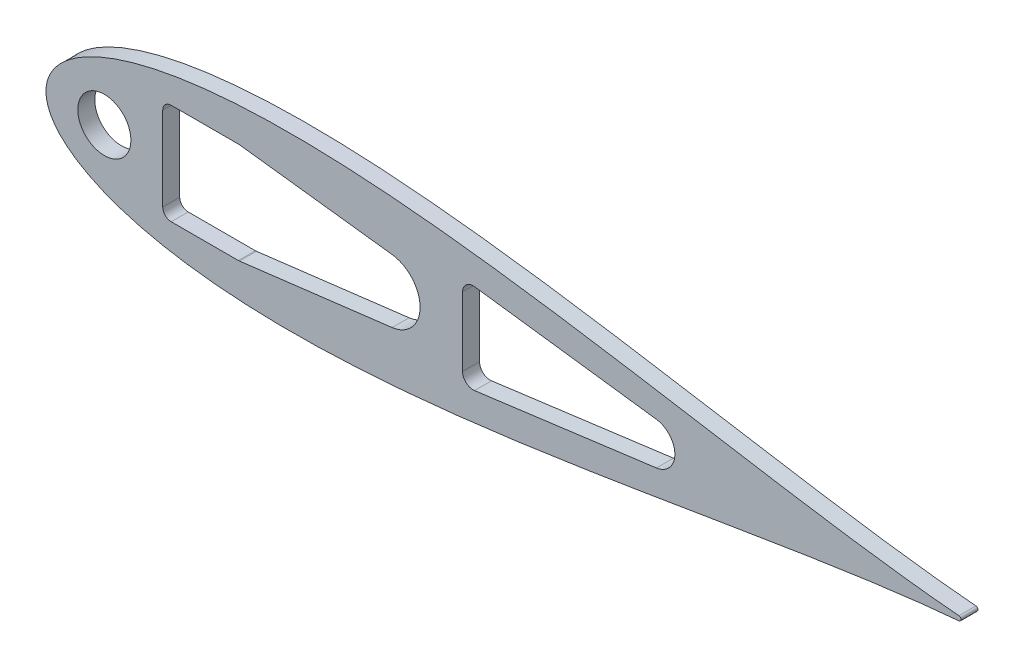
from build123d import *

# Parameters (mm, degrees)
BOSS_EXTRUDE1_DEPTH = 5.4737
SCALE1_SCALE        = 0.425
BOSS_EXTRUDE2_DEPTH = 5.08
SKETCH10_W          = 25.167167629
SKETCH10_H          = 30.1625
CUT_EXTRUDE6_DEPTH  = 6.0800001
FILLET1_R           = 2.54
CUT_EXTRUDE8_DEPTH  = 6.0800001
CUT_EXTRUDE9_DEPTH  = 6.0800001
SKETCH19_R          = 7.9375
CUT_EXTRUDE10_DEPTH = 6.0800001


with BuildPart() as part:
    # Sketch2 → Boss-Extrude1 (new body)
    with BuildSketch(Plane.XY):
        with BuildLine():
            add(Edge.make_bspline(
                [(642.510849283, 1.582039112), (641.993392355, 1.625070631), (638.093728429, 1.953546407), (630.413817462, 2.663385493), (619.014124193, 3.849253664), (606.374988512, 5.304428983), (592.543922516, 7.037634907), (577.585454095, 9.050636147), (561.564270734, 11.338919625), (544.549749946, 13.890665375), (526.614143658, 16.687720753), (507.832591566, 19.705111663), (488.282710288, 22.911672601), (468.044367735, 26.27043606), (447.199424328, 29.739007432), (425.831595832, 33.270324121), (404.02631566, 36.813220545), (381.870662856, 40.313266856), (359.453314895, 43.713502532), (336.86454415, 46.955447457), (314.196207315, 49.979843895), (291.541767704, 52.727712704), (268.996310773, 55.141201012), (246.65655865, 57.164603829), (224.620860897, 58.745176641), (202.989192599, 59.8341217), (181.863132616, 60.387506142), (161.345829027, 60.366961324), (141.542033828, 59.739895824), (122.558104573, 58.481758104), (104.502313427, 56.574303932), (87.485018636, 54.008935199), (71.619696083, 50.784752003), (57.023709725, 46.912543066), (43.82045433, 42.41500246), (32.141645239, 37.332204029), (22.129107375, 31.731455339), (13.932423524, 25.726412106), (7.689616489, 19.513207632), (3.463136343, 13.420354421), (1.106333228, 7.923389435), (0.154611582, 3.513796615), (-0.062151598, 0), (0.154611582, -3.513796615), (1.106333228, -7.923389435), (3.463136343, -13.420354421), (7.689616489, -19.513207632), (13.932423524, -25.726412106), (22.129107375, -31.731455339), (32.141645239, -37.332204029), (43.82045433, -42.41500246), (57.023709725, -46.912543066), (71.619696083, -50.784752003), (87.485018636, -54.008935199), (104.502313427, -56.574303932), (122.558104573, -58.481758104), (141.542033828, -59.739895824), (161.345829027, -60.366961324), (181.863132616, -60.387506142), (202.989192599, -59.8341217), (224.620860897, -58.745176641), (246.65655865, -57.164603829), (268.996310773, -55.141201012), (291.541767704, -52.727712704), (314.196207315, -49.979843895), (336.86454415, -46.955447457), (359.453314895, -43.713502532), (381.870662856, -40.313266856), (404.02631566, -36.813220545), (425.831595832, -33.270324121), (447.199424328, -29.739007432), (468.044367735, -26.27043606), (488.282710288, -22.911672601), (507.832591566, -19.705111663), (526.614143658, -16.687720753), (544.549749946, -13.890665375), (561.564270734, -11.338919625), (577.585454095, -9.050636147), (592.543922516, -7.037634907), (606.374988512, -5.304428983), (619.014124193, -3.849253664), (630.413817462, -2.663385493), (638.093728429, -1.953546407), (641.993392355, -1.625070631), (642.510849283, -1.582039112)],
                knots=[0.020157042, 0.020157042, 0.020157042, 0.020157042, 0.021270888, 0.028552555, 0.036780684, 0.045920102, 0.055931764, 0.066772884, 0.07839713, 0.090754827, 0.103793165, 0.117456432, 0.131686226, 0.146421738, 0.161599998, 0.177156133, 0.193023668, 0.209134786, 0.225420633, 0.241811602, 0.258237647, 0.274628557, 0.290914287, 0.307025229, 0.322892517, 0.338448342, 0.353626207, 0.368361232, 0.382590428, 0.396252961, 0.409290412, 0.42164701, 0.433269881, 0.444109249, 0.45411864, 0.463255055, 0.471479114, 0.478755289, 0.485052318, 0.490344026, 0.494609833, 0.497833231, 0.5, 0.502166769, 0.505390167, 0.509655974, 0.514947682, 0.521244711, 0.528520886, 0.536744945, 0.54588136, 0.555890751, 0.566730119, 0.57835299, 0.590709588, 0.603747039, 0.617409572, 0.631638768, 0.646373793, 0.661551658, 0.677107483, 0.692974771, 0.709085713, 0.725371443, 0.741762353, 0.758188398, 0.774579367, 0.790865214, 0.806976332, 0.822843867, 0.838400002, 0.853578262, 0.868313774, 0.882543568, 0.896206835, 0.909245173, 0.92160287, 0.933227116, 0.944068236, 0.954079898, 0.963219316, 0.971447445, 0.978729112, 0.979842958, 0.979842958, 0.979842958, 0.979842958], degree=3))
            ThreePointArc((642.510849283, -1.582039112), (643.966787522, 0), (642.510849283, 1.582039112))
        make_face()
    extrude(amount=BOSS_EXTRUDE1_DEPTH)


with BuildPart() as part_1:
    # Scale1: scaled about (0, 0, 0)
    add(part.part.scale(SCALE1_SCALE))

    # Sketch11 → Boss-Extrude2 (add)
    with BuildSketch(Plane(origin=(0, 0, 0), x_dir=(-1, 0, 0), z_dir=(0, 0, -1))):
        with BuildLine():
            ThreePointArc((-273.067110945, 0.672366623), (-273.685884697, 0), (-273.067110945, -0.672366623))
            add(Edge.make_bspline(
                [(-273.067110945, -0.672366623), (-272.847191751, -0.690655018), (-271.189834582, -0.830257223), (-267.925872421, -1.131938835), (-263.081002782, -1.635932807), (-257.709370118, -2.254382318), (-251.831167069, -2.990994836), (-245.473817991, -3.846520362), (-238.664815062, -4.819040841), (-231.433643727, -5.903532784), (-223.811011054, -7.09228132), (-215.828851416, -8.374672457), (-207.520151873, -9.737460855), (-198.918856287, -11.164935326), (-190.05975534, -12.639078159), (-180.978428229, -14.139887751), (-171.711184156, -15.645618732), (-162.295031714, -17.133138414), (-152.76765883, -18.578238576), (-143.167431264, -19.956065169), (-133.533388109, -21.241433655), (-123.905251274, -22.409277899), (-114.323432079, -23.43501043), (-104.829037426, -24.294956627), (-95.463865881, -24.966700073), (-86.270406855, -25.429501723), (-77.291831362, -25.66469011), (-68.571977336, -25.655958563), (-60.155364377, -25.389455725), (-52.087194443, -24.854747194), (-44.413483207, -24.044079171), (-37.18113292, -22.95379746), (-30.438370835, -21.583519601), (-24.235076633, -19.937830803), (-18.62369309, -18.026376046), (-13.660199227, -15.866186712), (-9.404870635, -13.485868519), (-5.921279998, -10.933725145), (-3.268087008, -8.293113244), (-1.471832946, -5.703650629), (-0.470191622, -3.36744051), (-0.065709922, -1.493363561), (0.026414429, 0), (-0.065709922, 1.493363561), (-0.470191622, 3.36744051), (-1.471832946, 5.703650629), (-3.268087008, 8.293113244), (-5.921279998, 10.933725145), (-9.404870635, 13.485868519), (-13.660199227, 15.866186712), (-18.62369309, 18.026376046), (-24.235076633, 19.937830803), (-30.438370835, 21.583519601), (-37.18113292, 22.95379746), (-44.413483207, 24.044079171), (-52.087194443, 24.854747194), (-60.155364377, 25.389455725), (-68.571977336, 25.655958563), (-77.291831362, 25.66469011), (-86.270406855, 25.429501723), (-95.463865881, 24.966700073), (-104.829037426, 24.294956627), (-114.323432079, 23.43501043), (-123.905251274, 22.409277899), (-133.533388109, 21.241433655), (-143.167431264, 19.956065169), (-152.76765883, 18.578238576), (-162.295031714, 17.133138414), (-171.711184156, 15.645618732), (-180.978428229, 14.139887751), (-190.05975534, 12.639078159), (-198.918856287, 11.164935326), (-207.520151873, 9.737460855), (-215.828851416, 8.374672457), (-223.811011054, 7.09228132), (-231.433643727, 5.903532784), (-238.664815062, 4.819040841), (-245.473817991, 3.846520362), (-251.831167069, 2.990994836), (-257.709370118, 2.254382318), (-263.081002782, 1.635932807), (-267.925872421, 1.131938835), (-271.189834582, 0.830257223), (-272.847191751, 0.690655018), (-273.067110945, 0.672366623)],
                knots=[0.020157042, 0.020157042, 0.020157042, 0.020157042, 0.021270888, 0.028552555, 0.036780684, 0.045920102, 0.055931764, 0.066772884, 0.07839713, 0.090754827, 0.103793165, 0.117456432, 0.131686226, 0.146421738, 0.161599998, 0.177156133, 0.193023668, 0.209134786, 0.225420633, 0.241811602, 0.258237647, 0.274628557, 0.290914287, 0.307025229, 0.322892517, 0.338448342, 0.353626207, 0.368361232, 0.382590428, 0.396252961, 0.409290412, 0.42164701, 0.433269881, 0.444109249, 0.45411864, 0.463255055, 0.471479114, 0.478755289, 0.485052318, 0.490344026, 0.494609833, 0.497833231, 0.5, 0.502166769, 0.505390167, 0.509655974, 0.514947682, 0.521244711, 0.528520886, 0.536744945, 0.54588136, 0.555890751, 0.566730119, 0.57835299, 0.590709588, 0.603747039, 0.617409572, 0.631638768, 0.646373793, 0.661551658, 0.677107483, 0.692974771, 0.709085713, 0.725371443, 0.741762353, 0.758188398, 0.774579367, 0.790865214, 0.806976332, 0.822843867, 0.838400002, 0.853578262, 0.868313774, 0.882543568, 0.896206835, 0.909245173, 0.92160287, 0.933227116, 0.944068236, 0.954079898, 0.963219316, 0.971447445, 0.978729112, 0.979842958, 0.979842958, 0.979842958, 0.979842958], degree=3))
        make_face()
    extrude(amount=-BOSS_EXTRUDE2_DEPTH)

    # Sketch10 → Cut-Extrude6 (cut, through all)
    with BuildSketch(Plane.XY):
        with Locations((47.508583814, 0)):
            Rectangle(SKETCH10_W, SKETCH10_H)
    extrude(amount=CUT_EXTRUDE6_DEPTH, mode=Mode.SUBTRACT)

    # Fillet1
    fillet1_edges = [part_1.edges().sort_by_distance(p)[0] for p in [
        (60.092167629, -15.08125, 2.54),
        (60.092167629, 15.08125, 2.54),
        (34.925, 15.08125, 2.54),
        (34.925, -15.08125, 2.54),
    ]]
    fillet(fillet1_edges, radius=FILLET1_R)

    # Sketch16 → Cut-Extrude8 (cut, through all)
    with BuildSketch(Plane.XY.offset(5.08)):
        with BuildLine():
            Line((102.372583815, -9.525), (100.594583815, -9.525))
            ThreePointArc((100.594583815, -9.525), (91.069583815, 0), (100.594583815, 9.525))
            Line((100.594583815, 9.525), (102.372583815, 9.525))
            ThreePointArc((102.372583815, 9.525), (111.897583815, 0), (102.372583815, -9.525))
        make_face()
    extrude(amount=-CUT_EXTRUDE8_DEPTH, mode=Mode.SUBTRACT)

    # Sketch18 → Cut-Extrude9 (cut, through all)
    with BuildSketch(Plane.XY.offset(5.08)):
        with BuildLine():
            Line((57.861745058, 15.062313628), (103.533499174, 9.453988604))
            ThreePointArc((103.533499174, 9.453988604), (111.897583815, 0), (103.533499174, -9.453988604))
            Line((103.533499174, -9.453988604), (57.861745058, -15.062313628))
            ThreePointArc((57.861745058, -15.062313628), (59.454524939, -14.224293869), (60.092167629, -12.54125))
            Line((60.092167629, -12.54125), (60.092167629, 12.54125))
            ThreePointArc((60.092167629, 12.54125), (59.454524939, 14.224293869), (57.861745058, 15.062313628))
        make_face()
    extrude(amount=-CUT_EXTRUDE9_DEPTH, mode=Mode.SUBTRACT)

    # Sketch19 → Cut-Extrude10 (cut, through all)
    with BuildSketch(Plane.XY.offset(5.08)):
        with Locations((17.4625, 0)):
            Circle(SKETCH19_R)
        with BuildLine():
            Line((128.187004475, 13.456177942), (182.576425135, 6.29567487))
            ThreePointArc((182.576425135, 6.29567487), (188.097583815, 0), (182.576425135, -6.29567487))
            Line((182.576425135, -6.29567487), (128.187004475, -13.456177942))
            ThreePointArc((128.187004475, -13.456177942), (125.679160852, -12.695431896), (124.597583815, -10.308340507))
            Line((124.597583815, -10.308340507), (124.597583815, 10.308340507))
            ThreePointArc((124.597583815, 10.308340507), (125.679160852, 12.695431896), (128.187004475, 13.456177942))
        make_face()
    extrude(amount=-CUT_EXTRUDE10_DEPTH, mode=Mode.SUBTRACT)


solid = part_1.part
